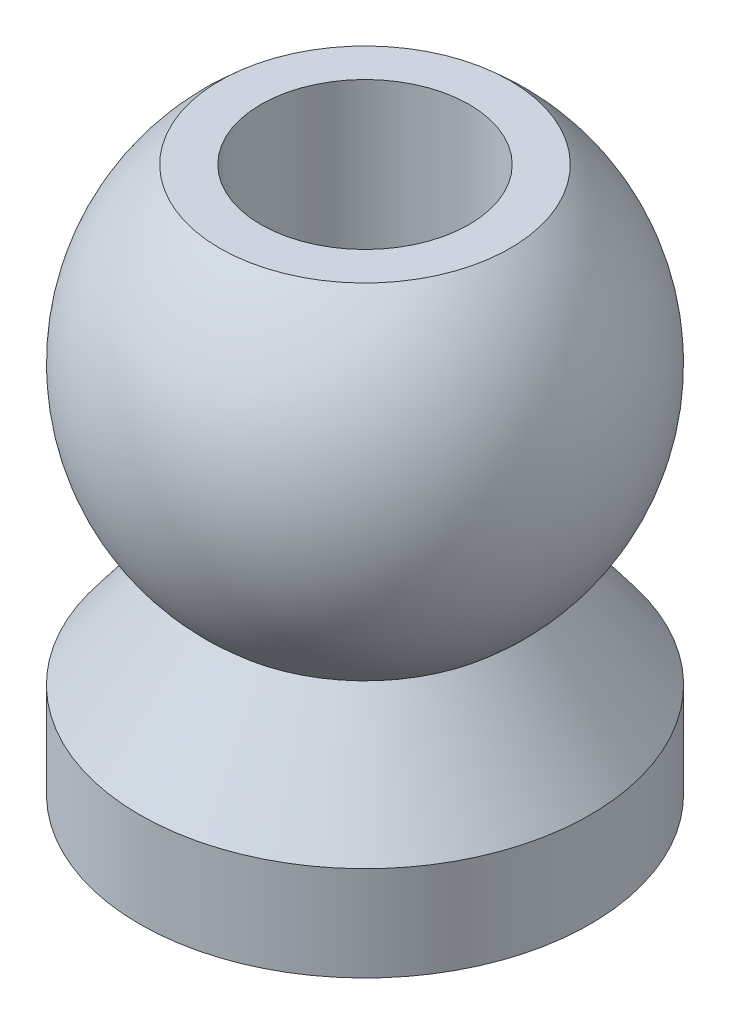
from build123d import *


with BuildPart() as part:
    # Sketch2 → Revolve2 (revolve)
    with BuildSketch(Plane.XY):
        with BuildLine():
            Line((-1.1, -3.94), (-2.38, -3.94))
            Line((-2.38, -3.94), (-2.38, -2.94))
            Line((-2.38, -2.94), (-1.533623161, -1.82))
            ThreePointArc((-1.533623161, -1.82), (-2.38, 0), (-1.533623161, 1.82))
            Line((-1.533623161, 1.82), (-1.1, 1.82))
            Line((-1.1, 1.82), (-1.1, -3.94))
        make_face()
    revolve(axis=Axis((0, 4.380472835, 0), (0, -1, 0)))


solid = part.part
